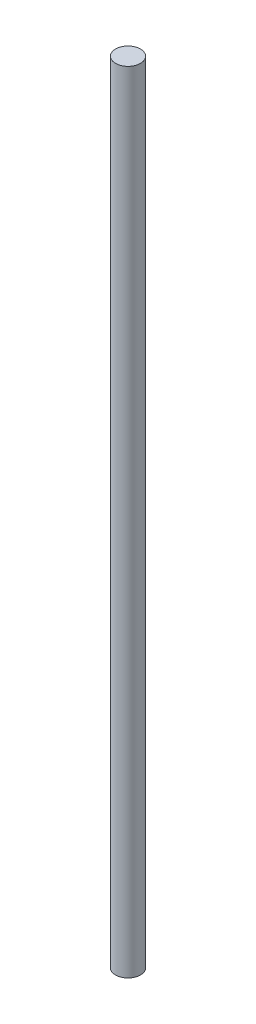
from build123d import *

# Parameters (mm, degrees)
SKETCH1_R           = 1.5
BOSS_EXTRUDE1_DEPTH = 95


with BuildPart() as part:
    # Sketch1 → Boss-Extrude1 (new body)
    with BuildSketch(Plane(origin=(0, 0, 0), x_dir=(1, 0, 0), z_dir=(0, 1, 0))):
        Circle(SKETCH1_R)
    extrude(amount=BOSS_EXTRUDE1_DEPTH)


solid = part.part
